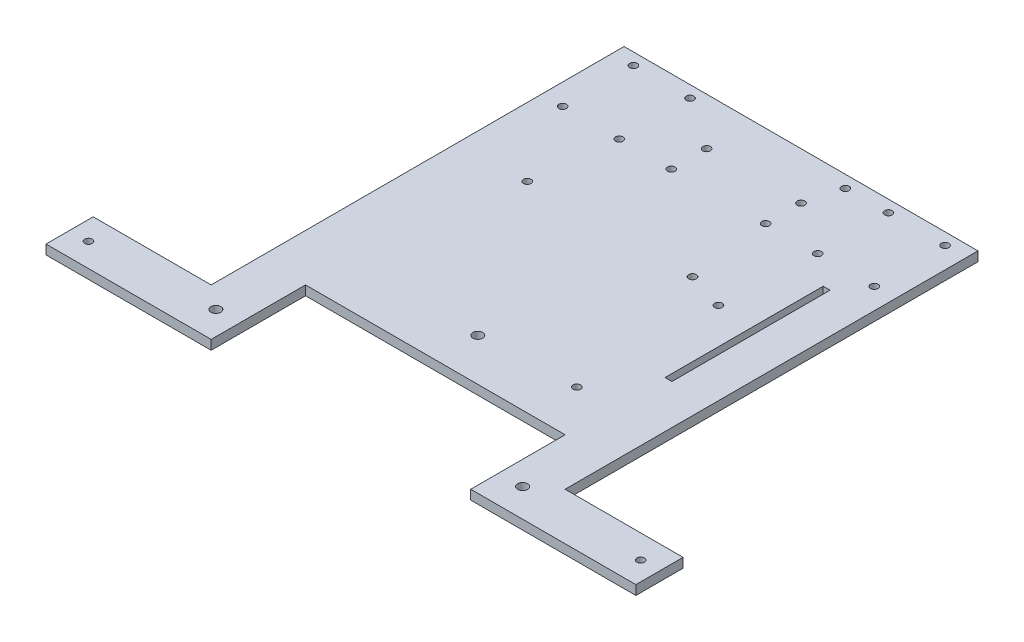
from build123d import *

# Parameters (mm, degrees)
SKETCH_1_W          = 150
SKETCH_1_H          = 145
SKETCH_1_R          = 1.6
SKETCH_1_W_2        = 2.916573318
SKETCH_1_H_2        = 67.038706503
EXTRUDE_1_DEPTH     = 4
SKETCH_2_R          = 2.1
SKETCH_2_R_2        = 1.6
CUT_EXTRUDE_1_DEPTH = 5
SKETCH_5_W          = 150
SKETCH_5_H          = 10
EXTRUDE_4_DEPTH     = 4
SKETCH_10_W         = 20
SKETCH_10_H         = 40
EXTRUDE_9_DEPTH     = 4
SKETCH_12_R         = 2.1
CUT_EXTRUDE_2_DEPTH = 5
SKETCH_15_W         = 50
SKETCH_15_H         = 20
SKETCH_15_R         = 1.6
EXTRUDE_11_DEPTH    = 4


with BuildPart() as part:
    # 草图1 → 凸台-拉伸1 (new body)
    with BuildSketch(Plane(origin=(0, 0, 0), x_dir=(1, 0, 0), z_dir=(0, 1, 0))):
        with Locations((0, -2.5)):
            Rectangle(SKETCH_1_W, SKETCH_1_H)
        with Locations((-20, 50)):
            Circle(SKETCH_1_R, mode=Mode.SUBTRACT)
        with Locations((20, 50)):
            Circle(SKETCH_1_R, mode=Mode.SUBTRACT)
        with Locations((-20, 35)):
            Circle(SKETCH_1_R, mode=Mode.SUBTRACT)
        with Locations((20, 35)):
            Circle(SKETCH_1_R, mode=Mode.SUBTRACT)
        with Locations((-46, 0)):
            Circle(SKETCH_1_R, mode=Mode.SUBTRACT)
        with Locations((24, 0)):
            Circle(SKETCH_1_R, mode=Mode.SUBTRACT)
        with Locations((24, 64.8)):
            Circle(SKETCH_1_R, mode=Mode.SUBTRACT)
        with Locations((40, -5)):
            Circle(SKETCH_1_R, mode=Mode.SUBTRACT)
        with Locations((40, -65)):
            Circle(SKETCH_1_R, mode=Mode.SUBTRACT)
        with Locations((56.637514727, -9.301063596)):
            Rectangle(SKETCH_1_W_2, SKETCH_1_H_2, mode=Mode.SUBTRACT)
    extrude(amount=EXTRUDE_1_DEPTH)

    # 草图2 → 切除-拉伸1 (cut, through all)
    with BuildSketch(Plane(origin=(0, 4, 0), x_dir=(1, 0, 0), z_dir=(0, 1, 0))):
        with Locations((0, -67)):
            Circle(SKETCH_2_R)
        with Locations((-66.052318668, 65)):
            Circle(SKETCH_2_R_2)
        with Locations((-66.052318668, 35)):
            Circle(SKETCH_2_R_2)
        with Locations((-42.052318668, 65)):
            Circle(SKETCH_2_R_2)
        with Locations((-42.052318668, 35)):
            Circle(SKETCH_2_R_2)
        with Locations((42.052318668, 35)):
            Circle(SKETCH_2_R_2)
        with Locations((66.052318668, 35)):
            Circle(SKETCH_2_R_2)
        with Locations((66.052318668, 65)):
            Circle(SKETCH_2_R_2)
        with Locations((42.052318668, 65)):
            Circle(SKETCH_2_R_2)
    extrude(amount=-CUT_EXTRUDE_1_DEPTH, mode=Mode.SUBTRACT)

    # 草图5 → 凸台-拉伸4 (add)
    with BuildSketch(Plane(origin=(0, 4, 0), x_dir=(1, 0, 0), z_dir=(0, 1, 0))):
        with Locations((0, -80)):
            Rectangle(SKETCH_5_W, SKETCH_5_H)
    extrude(amount=-EXTRUDE_4_DEPTH)

    # 草图10 → 凸台-拉伸9 (add)
    with BuildSketch(Plane.XZ):
        with Locations((-65, 105)):
            Rectangle(SKETCH_10_W, SKETCH_10_H)
        with Locations((65, 105)):
            Rectangle(SKETCH_10_W, SKETCH_10_H)
    extrude(amount=-EXTRUDE_9_DEPTH)

    # 草图12 → 切除-拉伸2 (cut, through all)
    with BuildSketch(Plane(origin=(0, 4, 0), x_dir=(1, 0, 0), z_dir=(0, 1, 0))):
        with Locations((-65, -113)):
            Circle(SKETCH_12_R)
        with Locations((65, -113)):
            Circle(SKETCH_12_R)
    extrude(amount=-CUT_EXTRUDE_2_DEPTH, mode=Mode.SUBTRACT)

    # 草图15 → 凸台-拉伸11 (add)
    with BuildSketch(Plane(origin=(0, 4, 0), x_dir=(1, 0, 0), z_dir=(0, 1, 0))):
        with Locations((100, -115)):
            Rectangle(SKETCH_15_W, SKETCH_15_H)
        with Locations((117, -115)):
            Circle(SKETCH_15_R, mode=Mode.SUBTRACT)
        with Locations((-100, -115)):
            Rectangle(SKETCH_15_W, SKETCH_15_H)
        with Locations((-117, -115)):
            Circle(SKETCH_15_R, mode=Mode.SUBTRACT)
    extrude(amount=-EXTRUDE_11_DEPTH)


solid = part.part
